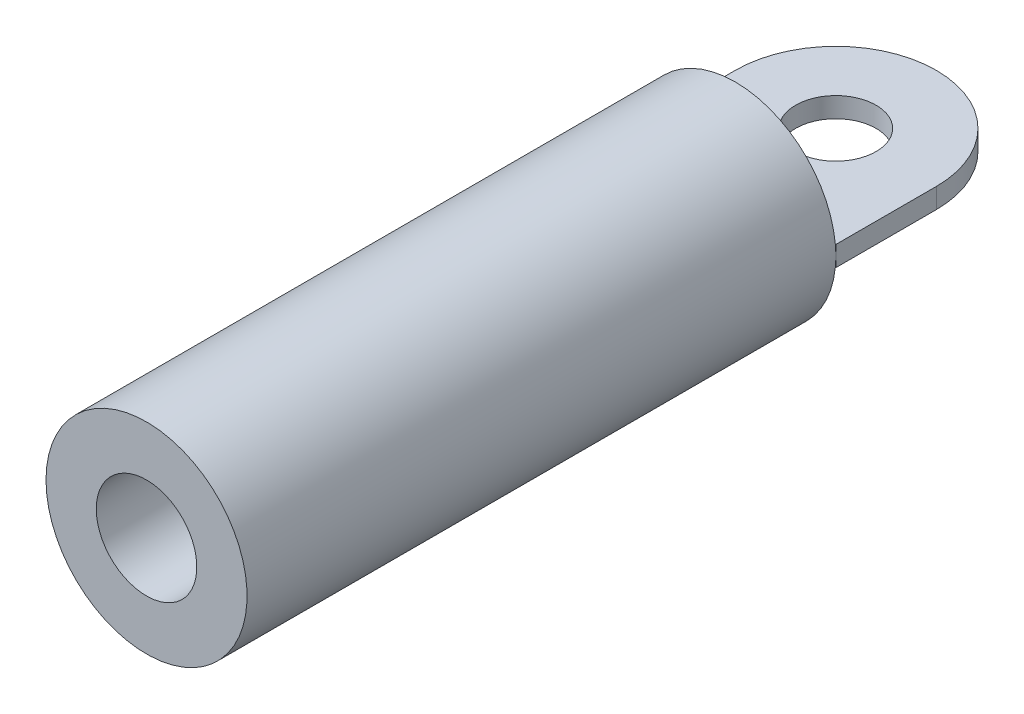
from build123d import *

# Parameters (mm, degrees)
SKETCH1_W                = 1.5875
SKETCH1_H                = 18.594090574
BOSS_EXTRUDE1_DEPTH      = 0.3175
BOSS_EXTRUDE1_DEPTH_BACK = 0.3175
SKETCH1_10_R             = 1.27


with BuildPart() as part:
    # Sketch1 → Revolve6 (revolve)
    with BuildSketch(Plane(origin=(0, 0, 0), x_dir=(1, 0, 0), z_dir=(0, 1, 0))):
        with Locations((-2.38125, -12.472045287)):
            Rectangle(SKETCH1_W, SKETCH1_H)
    revolve(axis=Axis((0, 0, 0), (0, 0, 1)))

    # Sketch1_10 → Boss-Extrude1 (add, two sides: drawn at the far end of the back side and taken through both)
    with BuildSketch(Plane(origin=(0, 0, 0), x_dir=(1, 0, 0), z_dir=(0, 1, 0)).offset(-BOSS_EXTRUDE1_DEPTH_BACK)):
        with BuildLine():
            Line((3.175, -3.175), (3.175, 0))
            ThreePointArc((3.175, 0), (0, 3.175), (-3.175, 0))
            Line((-3.175, 0), (-3.175, -3.175))
            Line((-3.175, -3.175), (3.175, -3.175))
        make_face()
        Circle(SKETCH1_10_R, mode=Mode.SUBTRACT)
    extrude(amount=BOSS_EXTRUDE1_DEPTH + BOSS_EXTRUDE1_DEPTH_BACK)


solid = part.part
